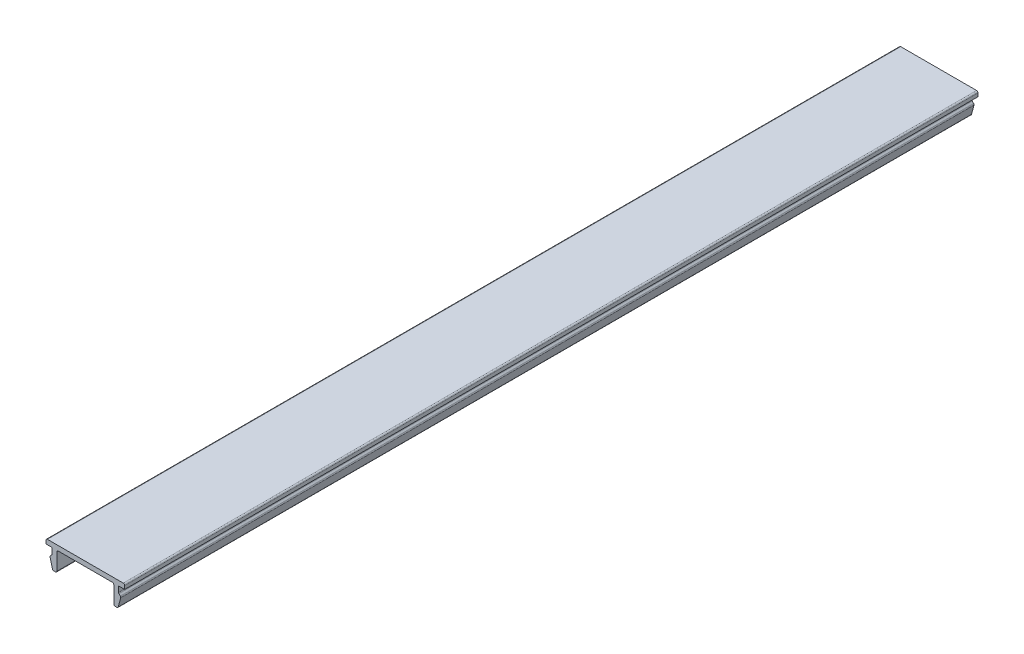
from build123d import *

# Parameters (mm, degrees)
BOSS_EXTRUDE1_DEPTH = 180
FILLET1_R           = 0.3


with BuildPart() as part:
    # Sketch1 → Boss-Extrude1 (new body)
    with BuildSketch(Plane.XY):
        Polygon((-8.3, 1), (8.3, 1), (8.3, 0), (7, 0), (7, -1.3), (7.5, -1.8), (6.883716857, -4.1), (6, -4.1), (6, 0), (-6, 0), (-6, -4.1), (-6.883716857, -4.1), (-7.5, -1.8), (-7, -1.3), (-7, 0), (-8.3, 0), align=None)
    extrude(amount=BOSS_EXTRUDE1_DEPTH)

    # Fillet1
    fillet1_edges = [part.edges().sort_by_distance(p)[0] for p in [
        (-8.3, 1, 90),
        (8.3, 1, 90),
        (7, -1.3, 90),
        (7.5, -1.8, 90),
        (6.883716857, -4.1, 90),
        (6, -4.1, 90),
        (6, 0, 90),
        (-6, 0, 90),
        (-6, -4.1, 90),
        (-6.883716857, -4.1, 90),
        (-7.5, -1.8, 90),
        (-7, -1.3, 90),
    ]]
    fillet(fillet1_edges, radius=FILLET1_R)


solid = part.part
